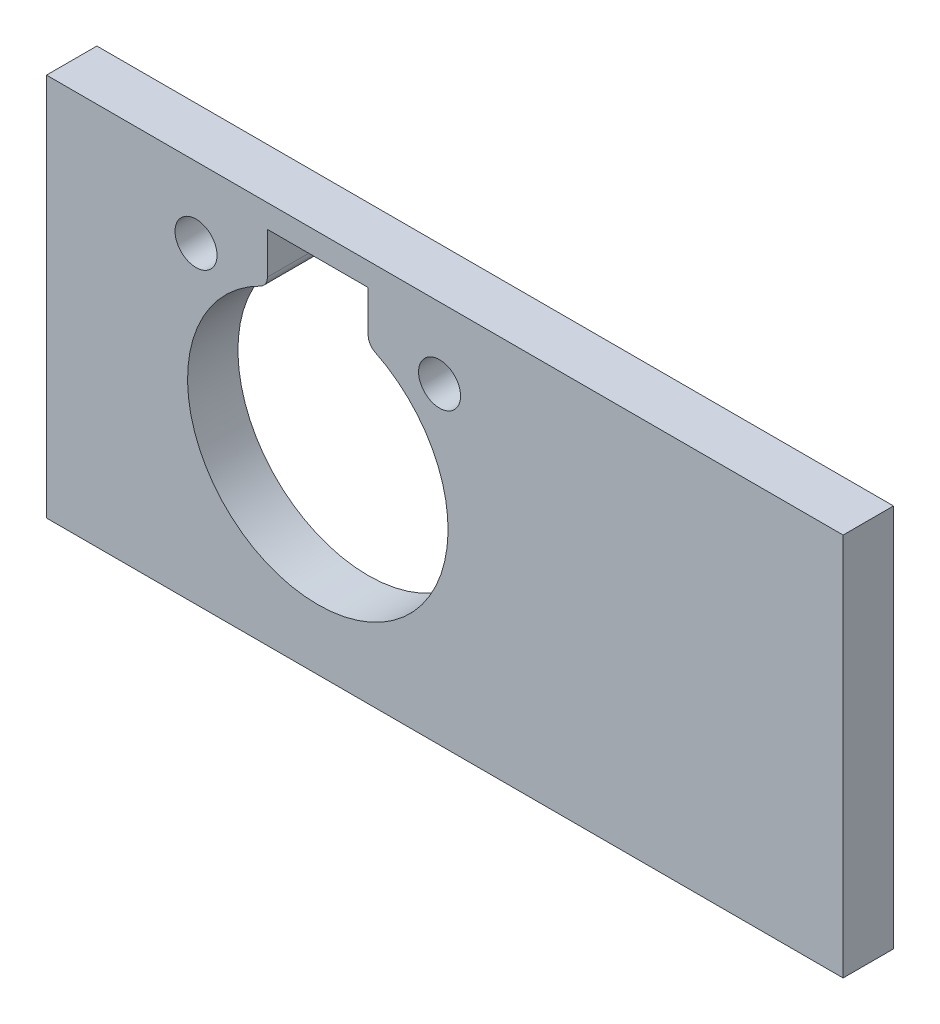
from build123d import *

# Parameters (mm, degrees)
SKETCH1_W           = 47.429010539
SKETCH1_H           = 22.84
BOSS_EXTRUDE1_DEPTH = 3
SKETCH2_R           = 1.25
CUT_EXTRUDE1_DEPTH  = 3


with BuildPart() as part:
    # Sketch1 → Boss-Extrude1 (new body)
    with BuildSketch(Plane.XY):
        with Locations((0.890297776, 4.627297895)):
            Rectangle(SKETCH1_W, SKETCH1_H)
    extrude(amount=BOSS_EXTRUDE1_DEPTH)

    # Sketch2 → Cut-Extrude1 (cut)
    with BuildSketch(Plane(origin=(0, 0, 0), x_dir=(-1, 0, 0), z_dir=(0, 0, -1))):
        with Locations((-0.578707914, 11.824797895)):
            Circle(SKETCH2_R)
        with Locations((13.921292086, 11.824797895)):
            Circle(SKETCH2_R)
        with BuildLine():
            Line((3.671803832, 14.669797895), (9.67078034, 14.669797895))
            Line((9.67078034, 14.669797895), (9.67078034, 12.208693547))
            ThreePointArc((9.67078034, 12.208693547), (9.784194907, 11.812134615), (10.090137637, 11.535510509))
            ThreePointArc((10.090137637, 11.535510509), (6.671292086, -3.180202105), (3.252446535, 11.535510509))
            ThreePointArc((3.252446535, 11.535510509), (3.558389265, 11.812134615), (3.671803832, 12.208693547))
            Line((3.671803832, 12.208693547), (3.671803832, 14.669797895))
        make_face()
    extrude(amount=-CUT_EXTRUDE1_DEPTH, mode=Mode.SUBTRACT)


solid = part.part
